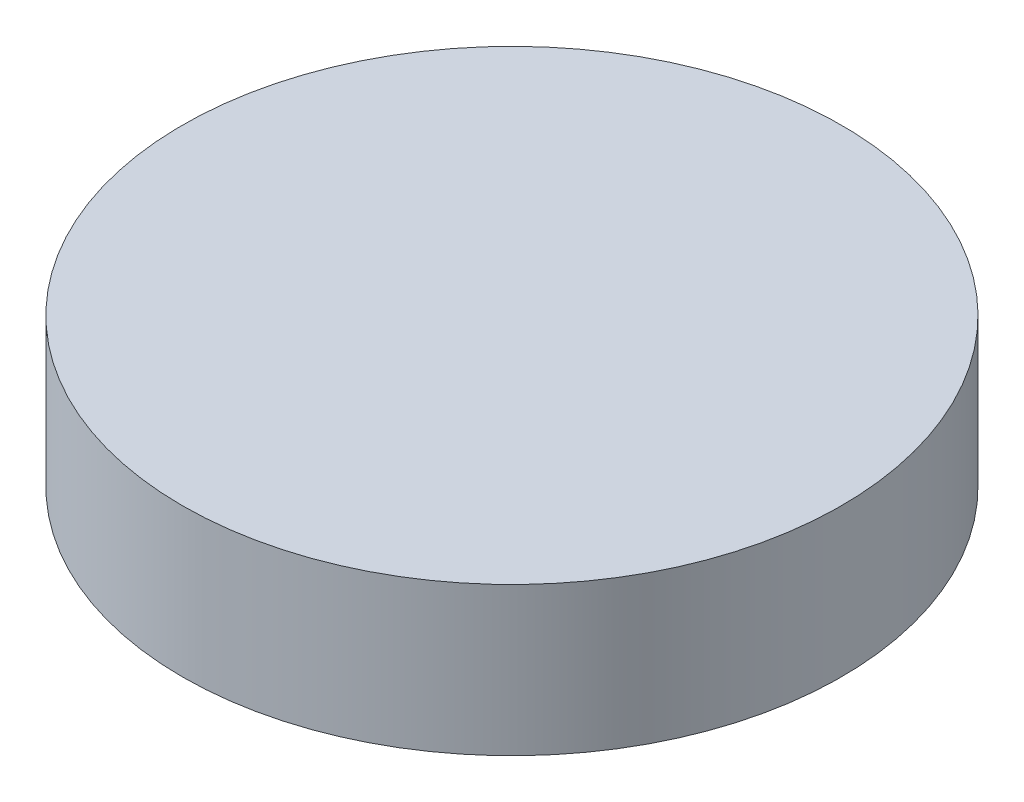
from build123d import *

# Parameters (mm, degrees)
SKETCH1_R           = 12.25
BOSS_EXTRUDE1_DEPTH = 5.5118


with BuildPart() as part:
    # Sketch1 → Boss-Extrude1 (new body)
    with BuildSketch(Plane(origin=(0, 0, 0), x_dir=(1, 0, 0), z_dir=(0, 1, 0))):
        Circle(SKETCH1_R)
    extrude(amount=BOSS_EXTRUDE1_DEPTH)


solid = part.part
